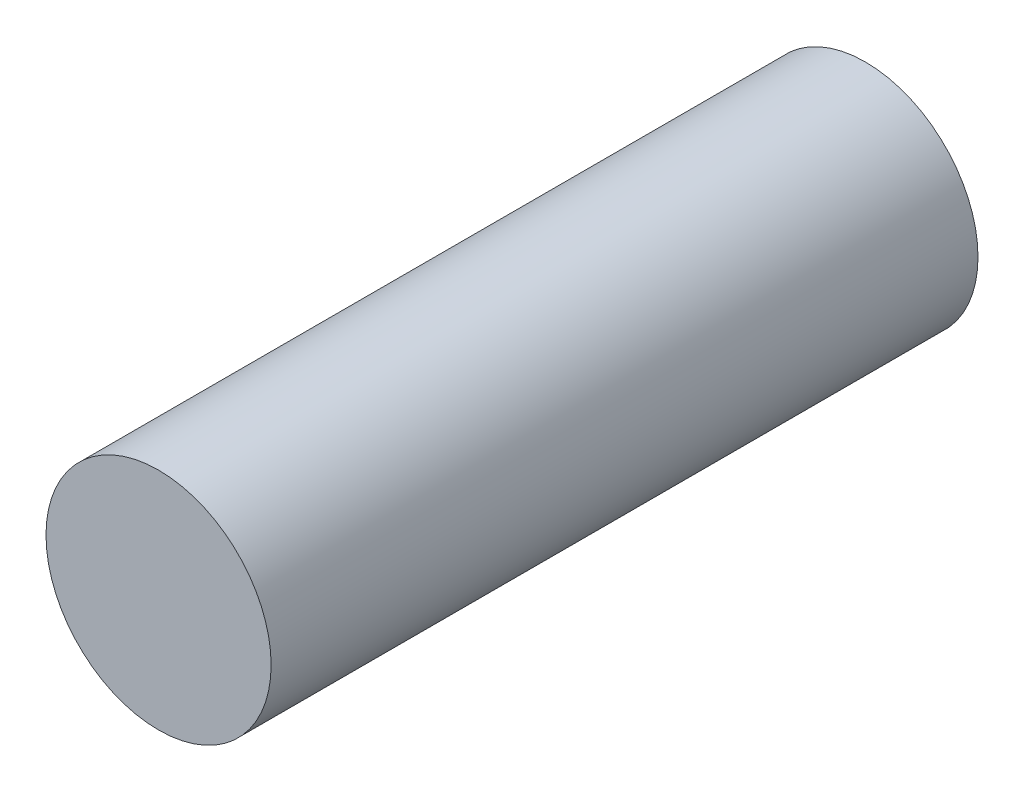
from build123d import *

# Parameters (mm, degrees)
SKETCH1_R           = 500
BOSS_EXTRUDE1_DEPTH = 3140


with BuildPart() as part:
    # Sketch1 → Boss-Extrude1 (new body)
    with BuildSketch(Plane.XY):
        Circle(SKETCH1_R)
    extrude(amount=BOSS_EXTRUDE1_DEPTH)


solid = part.part
